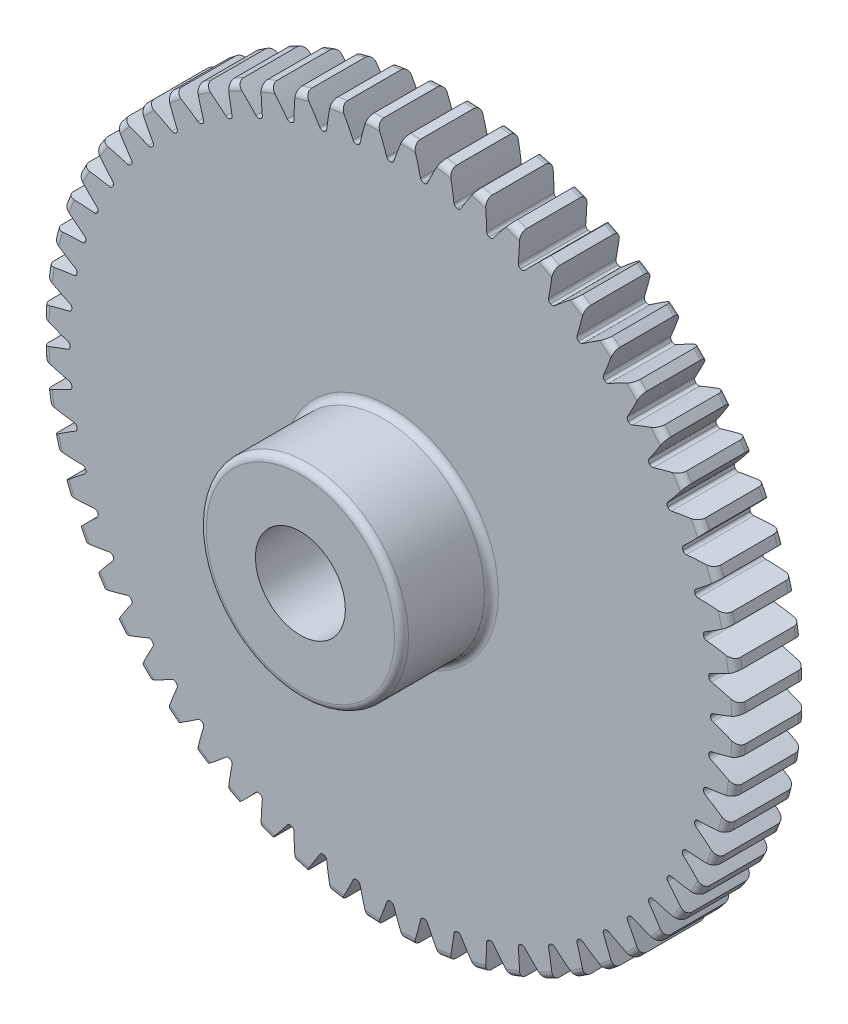
from build123d import *

# Parameters (mm, degrees)
FILLET2_R          = 0.62
CUT_EXTRUDE2_DEPTH = 7
CIRPATTERN1_COUNT  = 60


with BuildPart() as part:
    # Sketch4 → Revolve1 (revolve)
    with BuildSketch(Plane(origin=(0, 0, 0), x_dir=(0, 0, -1), z_dir=(1, 0, 0))):
        Polygon((-14, 4), (-14, 9), (-6, 9), (-6, 31), (0, 31), (0, 4), align=None)
    revolve(axis=Axis((0, 0, 6), (0, 0, 1)))

    # Fillet2
    fillet2_edges = [part.edges().sort_by_distance(p)[0] for p in [
        (0, -31, 0),
        (0, -31, 6),
        (0, -9, 6),
        (0, -9, 14),
    ]]
    fillet(fillet2_edges, radius=FILLET2_R)

    # Sketch7 → Cut-Extrude2 (cut, through all)
    with BuildSketch(Plane.XY.offset(6)):
        with BuildLine():
            ThreePointArc((-0.027924152, 28.49998632), (0, 28.5), (0.027924152, 28.49998632))
            ThreePointArc((0.027924152, 28.49998632), (0.20257511, 28.555850808), (0.31209617, 28.702918602))
            ThreePointArc((0.31209617, 28.702918602), (0.730254377, 29.848919172), (1.194657711, 30.976971978))
            ThreePointArc((1.194657711, 30.976971978), (0, 31), (-1.194657711, 30.976971978))
            ThreePointArc((-1.194657711, 30.976971978), (-0.730254377, 29.848919172), (-0.31209617, 28.702918602))
            ThreePointArc((-0.31209617, 28.702918602), (-0.20257511, 28.555850808), (-0.027924152, 28.49998632))
        make_face()
    cut_extrude2 = extrude(amount=-CUT_EXTRUDE2_DEPTH, mode=Mode.SUBTRACT)

    # CirPattern1: Cut-Extrude2 ×60 about axis
    cirpattern1_axis = Axis((0, 0, 0), (0, 0, 1))
    for i in range(1, CIRPATTERN1_COUNT):
        add(cut_extrude2.rotate(cirpattern1_axis, i * 360 / CIRPATTERN1_COUNT), mode=Mode.SUBTRACT)


solid = part.part
